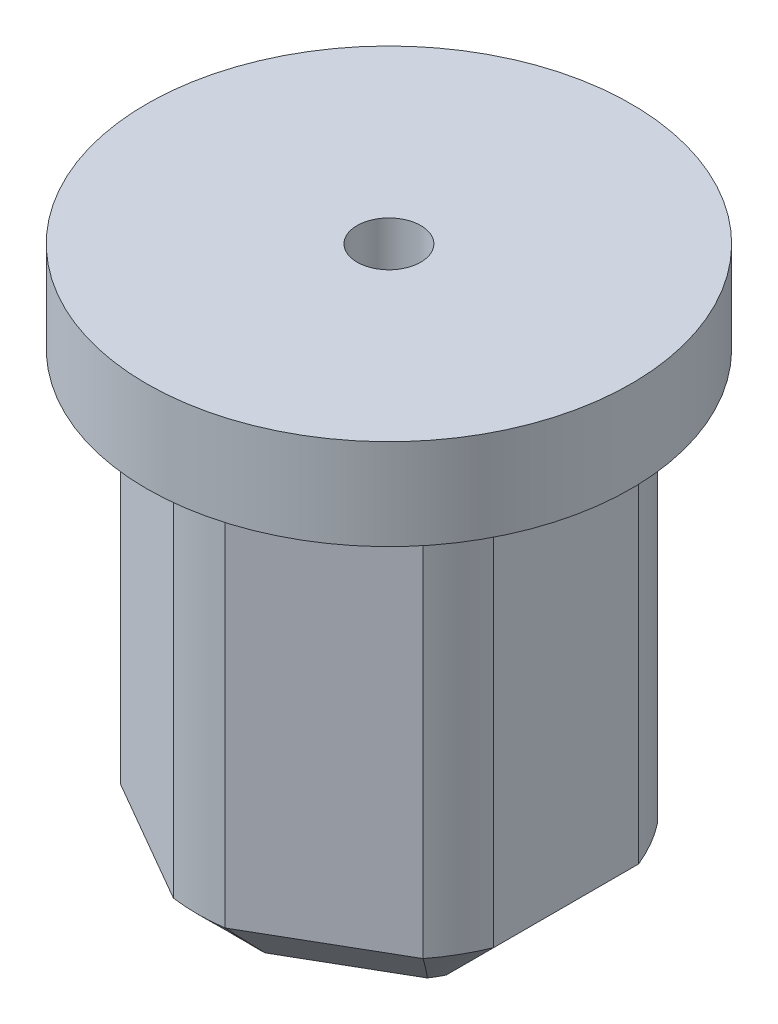
from build123d import *

# Parameters (mm, degrees)
SKETCH1_R           = 8
BOSS_EXTRUDE1_DEPTH = 3
BOSS_EXTRUDE2_DEPTH = 15
CHAMFER1_SIZE       = 2
SKETCH10_R          = 2.5
CUT_EXTRUDE1_DEPTH  = 15
SKETCH11_R          = 1.05
CUT_EXTRUDE3_DEPTH  = 19


with BuildPart() as part:
    # Sketch1 → Boss-Extrude1 (new body)
    with BuildSketch(Plane(origin=(0, 0, 0), x_dir=(1, 0, 0), z_dir=(0, 1, 0))):
        Circle(SKETCH1_R)
    extrude(amount=BOSS_EXTRUDE1_DEPTH)

    # Sketch9 → Boss-Extrude2 (add)
    with BuildSketch(Plane.XZ):
        with BuildLine():
            ThreePointArc((-0.853786588, -6.262064233), (0, -6.32), (0.853786588, -6.262064233))
            Line((0.853786588, -6.262064233), (4.996213412, -3.870432991))
            ThreePointArc((4.996213412, -3.870432991), (5.473280552, -3.16), (5.85, -2.391631242))
            Line((5.85, -2.391631242), (5.85, 2.391631242))
            ThreePointArc((5.85, 2.391631242), (5.473280552, 3.16), (4.996213412, 3.870432991))
            Line((4.996213412, 3.870432991), (0.853786588, 6.262064233))
            ThreePointArc((0.853786588, 6.262064233), (0, 6.32), (-0.853786588, 6.262064233))
            Line((-0.853786588, 6.262064233), (-4.996213412, 3.870432991))
            ThreePointArc((-4.996213412, 3.870432991), (-5.473280552, 3.16), (-5.85, 2.391631242))
            Line((-5.85, 2.391631242), (-5.85, -2.391631242))
            ThreePointArc((-5.85, -2.391631242), (-5.473280552, -3.16), (-4.996213412, -3.870432991))
            Line((-4.996213412, -3.870432991), (-0.853786588, -6.262064233))
        make_face()
    extrude(amount=BOSS_EXTRUDE2_DEPTH)

    # Chamfer1
    chamfer1_edges = [part.edges().sort_by_distance(p)[0] for p in [
        (2.925, -15, -5.066248612),
        (5.473280552, -15, -3.16),
        (5.85, -15, 0),
        (5.473280552, -15, 3.16),
        (2.925, -15, 5.066248612),
        (0, -15, 6.32),
        (-2.925, -15, 5.066248612),
        (-5.473280552, -15, 3.16),
        (-5.85, -15, 0),
        (-5.473280552, -15, -3.16),
        (-2.925, -15, -5.066248612),
        (0, -15, -6.32),
    ]]
    chamfer(chamfer1_edges, length=CHAMFER1_SIZE)

    # Sketch10 → Cut-Extrude1 (cut)
    with BuildSketch(Plane.XZ.offset(15)):
        Circle(SKETCH10_R)
    extrude(amount=-CUT_EXTRUDE1_DEPTH, mode=Mode.SUBTRACT)

    # Sketch11 → Cut-Extrude3 (cut, through all)
    with BuildSketch(Plane(origin=(0, 3, 0), x_dir=(1, 0, 0), z_dir=(0, 1, 0))):
        Circle(SKETCH11_R)
    extrude(amount=-CUT_EXTRUDE3_DEPTH, mode=Mode.SUBTRACT)


solid = part.part
